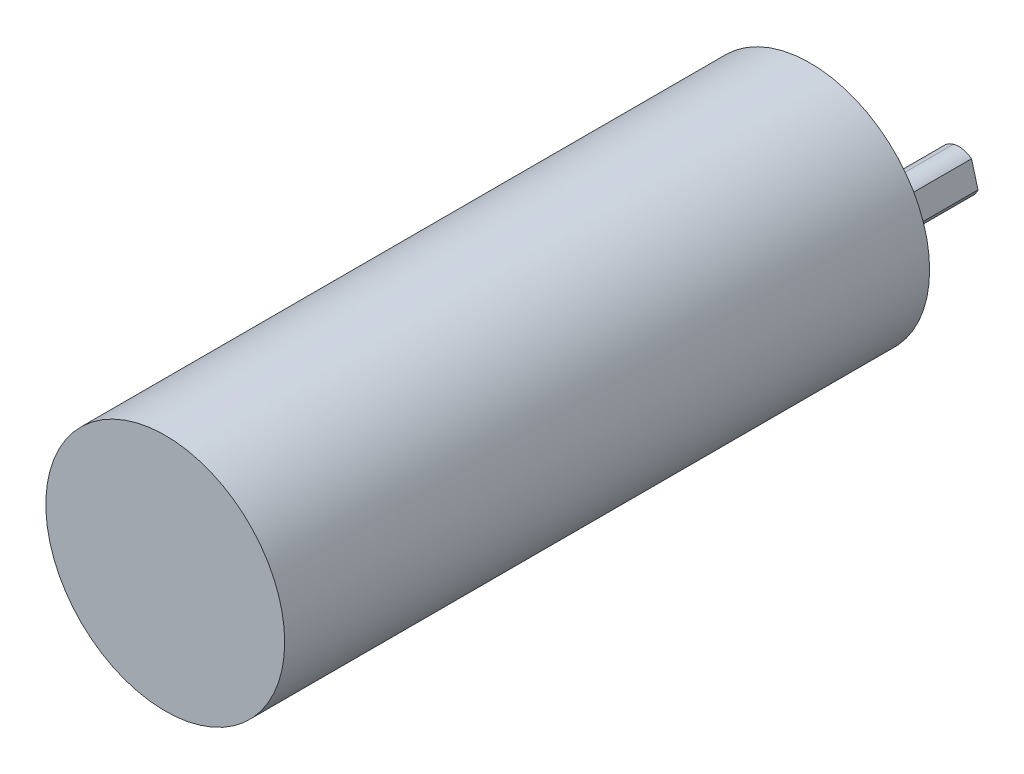
from build123d import *

# Parameters (mm, degrees)
SKETCH1_R           = 1.5
BOSS_EXTRUDE1_DEPTH = 94.5
BOSS_EXTRUDE3_DEPTH = 6.3
BOSS_EXTRUDE4_DEPTH = 21.8
SKETCH1_6_R         = 1.5
CUT_EXTRUDE1_DEPTH  = 10


with BuildPart() as part:
    # Sketch1 → Boss-Extrude1 (new body)
    with BuildSketch(Plane.XY):
        with BuildLine():
            ThreePointArc((0, 74), (17.499999998, 91.499999997), (0, 108.999999994))
            ThreePointArc((0, 108.999999994), (-17.499999997, 91.499999997), (0, 74))
        make_face()
        with Locations((12.817814144, 84.099631551)):
            Circle(SKETCH1_R, mode=Mode.SUBTRACT)
        with Locations((-12.817814143, 84.099631551)):
            Circle(SKETCH1_R, mode=Mode.SUBTRACT)
        with Locations((0, 106.30073689)):
            Circle(SKETCH1_R, mode=Mode.SUBTRACT)
        with BuildLine():
            ThreePointArc((-1e-09, 77.999999997), (6.5, 84.499999997), (0, 90.999999997))
            ThreePointArc((0, 90.999999997), (-6.5, 84.499999998), (-1e-09, 77.999999997))
        make_face(mode=Mode.SUBTRACT)
        with Locations((-12.817814143, 84.099631551)):
            Circle(SKETCH1_R)
        with BuildLine():
            ThreePointArc((0, 90.999999997), (-6.5, 84.499999998), (-1e-09, 77.999999997))
            ThreePointArc((-1e-09, 77.999999997), (6.5, 84.499999997), (0, 90.999999997))
        make_face()
        with BuildLine():
            add(Edge.make_bspline(
                [(-0.789016214, 87.394383075), (-0.836251367, 87.380790397), (-0.930607605, 87.353637864), (-1.069336131, 87.304188837), (-1.205616846, 87.24844995), (-1.383425221, 87.165115004), (-1.597856288, 87.044837702), (-1.919837751, 86.819824343), (-2.278742073, 86.480897933), (-2.621326987, 85.998323085), (-2.863289696, 85.45812482), (-2.995187241, 84.881118066), (-3.011989651, 84.289462006), (-2.913040637, 83.705897706), (-2.702146266, 83.152849852), (-2.387407645, 82.65157316), (-1.980930255, 82.221327185), (-1.49829726, 81.878661532), (-0.958195814, 81.636686952), (-0.476965962, 81.526852591), (-0.085285333, 81.496243835), (0.20943739, 81.502853331), (0.502671967, 81.536156329), (0.693568135, 81.58246339), (0.789016219, 81.60561692)],
                knots=[0, 0, 0, 0, 0.015662531, 0.031287238, 0.046911945, 0.062574476, 0.09385228, 0.125130083, 0.187609975, 0.250089867, 0.312569759, 0.375049651, 0.437529543, 0.500009434, 0.562489326, 0.624969218, 0.68744911, 0.749929002, 0.812408893, 0.874888785, 0.906166589, 0.937444393, 0.968722196, 1, 1, 1, 1], degree=3))
            add(Edge.make_bspline(
                [(0.789016219, 81.60561692), (0.84477437, 81.621812565), (0.956102809, 81.654149289), (1.119086683, 81.714775887), (1.278484956, 81.784122691), (1.485257077, 81.889018732), (1.732087443, 82.042116211), (2.004527497, 82.259094254), (2.250552695, 82.505769883), (2.465352752, 82.77975889), (2.650058966, 83.075549571), (2.742630451, 83.288238605), (2.788916194, 83.394583122)],
                knots=[0, 0, 0, 0, 0.062625218, 0.125039437, 0.187453656, 0.250078874, 0.375065728, 0.500052583, 0.625039437, 0.750026292, 0.875013146, 1, 1, 1, 1], degree=3))
            Line((2.788916194, 83.394583122), (1.842096733, 86.86784282))
            add(Edge.make_bspline(
                [(1.842096733, 86.86784282), (1.795685326, 86.902731953), (1.703018884, 86.97239267), (1.55672728, 87.066403809), (1.405610874, 87.152314344), (1.197630767, 87.254794412), (0.927054567, 87.360400226), (0.590008097, 87.44816544), (0.245052476, 87.496980218), (-0.103018764, 87.504426869), (-0.450475036, 87.474717423), (-0.676169155, 87.421161191), (-0.789016214, 87.394383075)],
                knots=[0, 0, 0, 0, 0.062625218, 0.125039437, 0.187453656, 0.250078874, 0.375065728, 0.500052583, 0.625039437, 0.750026291, 0.875013146, 1, 1, 1, 1], degree=3))
        make_face(mode=Mode.SUBTRACT)
        with BuildLine():
            add(Edge.make_bspline(
                [(1.842096733, 86.86784282), (1.795685326, 86.902731953), (1.703018884, 86.97239267), (1.55672728, 87.066403809), (1.405610874, 87.152314344), (1.197630767, 87.254794412), (0.927054567, 87.360400226), (0.590008097, 87.44816544), (0.245052476, 87.496980218), (-0.103018764, 87.504426869), (-0.450475036, 87.474717423), (-0.676169155, 87.421161191), (-0.789016214, 87.394383075)],
                knots=[0, 0, 0, 0, 0.062625218, 0.125039437, 0.187453656, 0.250078874, 0.375065728, 0.500052583, 0.625039437, 0.750026291, 0.875013146, 1, 1, 1, 1], degree=3))
            add(Edge.make_bspline(
                [(-0.789016214, 87.394383075), (-0.836251367, 87.380790397), (-0.930607605, 87.353637864), (-1.069336131, 87.304188837), (-1.205616846, 87.24844995), (-1.383425221, 87.165115004), (-1.597856288, 87.044837702), (-1.919837751, 86.819824343), (-2.278742073, 86.480897933), (-2.621326987, 85.998323085), (-2.863289696, 85.45812482), (-2.995187241, 84.881118066), (-3.011989651, 84.289462006), (-2.913040637, 83.705897706), (-2.702146266, 83.152849852), (-2.387407645, 82.65157316), (-1.980930255, 82.221327185), (-1.49829726, 81.878661532), (-0.958195814, 81.636686952), (-0.476965962, 81.526852591), (-0.085285333, 81.496243835), (0.20943739, 81.502853331), (0.502671967, 81.536156329), (0.693568135, 81.58246339), (0.789016219, 81.60561692)],
                knots=[0, 0, 0, 0, 0.015662531, 0.031287238, 0.046911945, 0.062574476, 0.09385228, 0.125130083, 0.187609975, 0.250089867, 0.312569759, 0.375049651, 0.437529543, 0.500009434, 0.562489326, 0.624969218, 0.68744911, 0.749929002, 0.812408893, 0.874888785, 0.906166589, 0.937444393, 0.968722196, 1, 1, 1, 1], degree=3))
            add(Edge.make_bspline(
                [(0.789016219, 81.60561692), (0.84477437, 81.621812565), (0.956102809, 81.654149289), (1.119086683, 81.714775887), (1.278484956, 81.784122691), (1.485257077, 81.889018732), (1.732087443, 82.042116211), (2.004527497, 82.259094254), (2.250552695, 82.505769883), (2.465352752, 82.77975889), (2.650058966, 83.075549571), (2.742630451, 83.288238605), (2.788916194, 83.394583122)],
                knots=[0, 0, 0, 0, 0.062625218, 0.125039437, 0.187453656, 0.250078874, 0.375065728, 0.500052583, 0.625039437, 0.750026292, 0.875013146, 1, 1, 1, 1], degree=3))
            Line((2.788916194, 83.394583122), (1.842096733, 86.86784282))
        make_face()
        with Locations((12.817814144, 84.099631551)):
            Circle(SKETCH1_R)
        with Locations((0, 106.30073689)):
            Circle(SKETCH1_R)
    extrude(amount=BOSS_EXTRUDE1_DEPTH)

    # Sketch1_4 → Boss-Extrude3 (add)
    with BuildSketch(Plane.XY):
        with BuildLine():
            ThreePointArc((0, 90.999999997), (-6.5, 84.499999998), (-1e-09, 77.999999997))
            ThreePointArc((-1e-09, 77.999999997), (6.5, 84.499999997), (0, 90.999999997))
        make_face()
    extrude(amount=-BOSS_EXTRUDE3_DEPTH)

    # Sketch1_5 → Boss-Extrude4 (add)
    with BuildSketch(Plane.XY):
        with BuildLine():
            Line((2.788916194, 83.394583122), (1.842096733, 86.86784282))
            add(Edge.make_bspline(
                [(1.842096733, 86.86784282), (1.795685326, 86.902731953), (1.703018884, 86.97239267), (1.55672728, 87.066403809), (1.405610874, 87.152314344), (1.197630767, 87.254794412), (0.927054567, 87.360400226), (0.590008097, 87.44816544), (0.245052476, 87.496980218), (-0.103018764, 87.504426869), (-0.450475036, 87.474717423), (-0.676169155, 87.421161191), (-0.789016214, 87.394383075)],
                knots=[0, 0, 0, 0, 0.062625218, 0.125039437, 0.187453656, 0.250078874, 0.375065728, 0.500052583, 0.625039437, 0.750026291, 0.875013146, 1, 1, 1, 1], degree=3))
            add(Edge.make_bspline(
                [(-0.789016214, 87.394383075), (-0.836251367, 87.380790397), (-0.930607605, 87.353637864), (-1.069336131, 87.304188837), (-1.205616846, 87.24844995), (-1.383425221, 87.165115004), (-1.597856288, 87.044837702), (-1.919837751, 86.819824343), (-2.278742073, 86.480897933), (-2.621326987, 85.998323085), (-2.863289696, 85.45812482), (-2.995187241, 84.881118066), (-3.011989651, 84.289462006), (-2.913040637, 83.705897706), (-2.702146266, 83.152849852), (-2.387407645, 82.65157316), (-1.980930255, 82.221327185), (-1.49829726, 81.878661532), (-0.958195814, 81.636686952), (-0.476965962, 81.526852591), (-0.085285333, 81.496243835), (0.20943739, 81.502853331), (0.502671967, 81.536156329), (0.693568135, 81.58246339), (0.789016219, 81.60561692)],
                knots=[0, 0, 0, 0, 0.015662531, 0.031287238, 0.046911945, 0.062574476, 0.09385228, 0.125130083, 0.187609975, 0.250089867, 0.312569759, 0.375049651, 0.437529543, 0.500009434, 0.562489326, 0.624969218, 0.68744911, 0.749929002, 0.812408893, 0.874888785, 0.906166589, 0.937444393, 0.968722196, 1, 1, 1, 1], degree=3))
            add(Edge.make_bspline(
                [(0.789016219, 81.60561692), (0.84477437, 81.621812565), (0.956102809, 81.654149289), (1.119086683, 81.714775887), (1.278484956, 81.784122691), (1.485257077, 81.889018732), (1.732087443, 82.042116211), (2.004527497, 82.259094254), (2.250552695, 82.505769883), (2.465352752, 82.77975889), (2.650058966, 83.075549571), (2.742630451, 83.288238605), (2.788916194, 83.394583122)],
                knots=[0, 0, 0, 0, 0.062625218, 0.125039437, 0.187453656, 0.250078874, 0.375065728, 0.500052583, 0.625039437, 0.750026292, 0.875013146, 1, 1, 1, 1], degree=3))
        make_face()
    extrude(amount=-BOSS_EXTRUDE4_DEPTH)

    # Sketch1_6 → Cut-Extrude1 (cut)
    with BuildSketch(Plane.XY):
        with Locations((0, 106.30073689)):
            Circle(SKETCH1_6_R)
        with Locations((-12.817814143, 84.099631551)):
            Circle(SKETCH1_6_R)
        with Locations((12.817814144, 84.099631551)):
            Circle(SKETCH1_6_R)
    extrude(amount=CUT_EXTRUDE1_DEPTH, mode=Mode.SUBTRACT)


solid = part.part
